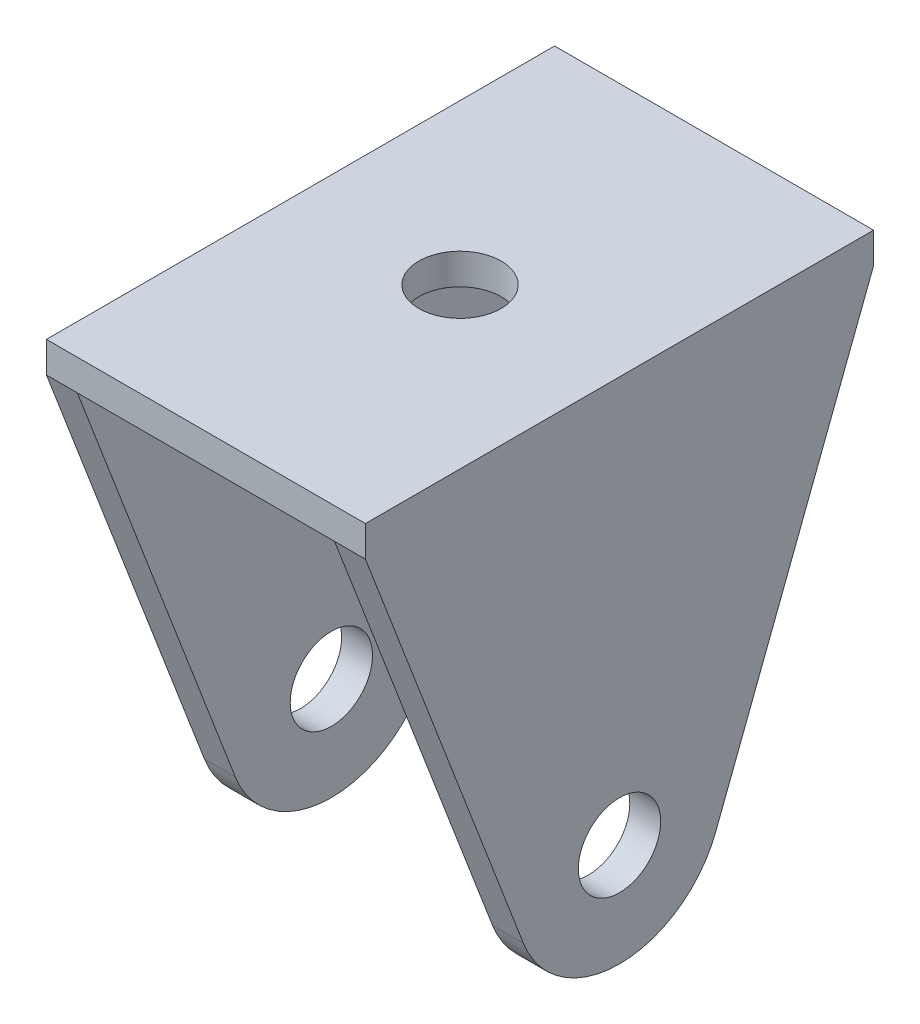
from build123d import *

# Parameters (mm, degrees)
CROQUIS1_R              = 4
SALIENTE_EXTRUIR1_DEPTH = 3
CROQUIS2_R              = 4
SALIENTE_EXTRUIR2_DEPTH = 3
CROQUIS3_W              = 31
CROQUIS3_H              = 49.380731332
SALIENTE_EXTRUIR3_DEPTH = 3
CROQUIS5_R              = 4
CORTAR_EXTRUIR1_DEPTH   = 3


with BuildPart() as part:
    # Croquis1 → Saliente-Extruir1 (new body)
    with BuildSketch(Plane(origin=(0, 0, 0), x_dir=(0, 0, -1), z_dir=(1, 0, 0))):
        with BuildLine():
            Line((-9.335804265, -3.583679495), (-24.690365666, 36.416320505))
            Line((-24.690365666, 36.416320505), (24.690365666, 36.416320505))
            Line((24.690365666, 36.416320505), (9.335804265, -3.583679495))
            ThreePointArc((9.335804265, -3.583679495), (0, -10), (-9.335804265, -3.583679495))
        make_face()
        Circle(CROQUIS1_R, mode=Mode.SUBTRACT)
    extrude(amount=SALIENTE_EXTRUIR1_DEPTH)



with BuildPart() as body_2:
    # Croquis2 → Saliente-Extruir2 (new body)
    with BuildSketch(Plane.ZY.offset(25)):
        with BuildLine():
            Line((9.335804265, -3.583679495), (24.690365666, 36.416320505))
            Line((24.690365666, 36.416320505), (-24.690365666, 36.416320505))
            Line((-24.690365666, 36.416320505), (-9.335804265, -3.583679495))
            ThreePointArc((-9.335804265, -3.583679495), (0, -10), (9.335804265, -3.583679495))
        make_face()
        Circle(CROQUIS2_R, mode=Mode.SUBTRACT)
    extrude(amount=SALIENTE_EXTRUIR2_DEPTH)


with BuildPart() as part_1:
    add(part.part)

    add(body_2.part)  # Saliente-Extruir3 merges body 2
    # Croquis3 → Saliente-Extruir3 (add)
    with BuildSketch(Plane(origin=(0, 36.416320505, 0), x_dir=(1, 0, 0), z_dir=(0, 1, 0))):
        with Locations((-12.5, 0)):
            Rectangle(CROQUIS3_W, CROQUIS3_H)
    extrude(amount=SALIENTE_EXTRUIR3_DEPTH)

    # Croquis5 → Cortar-Extruir1 (cut)
    with BuildSketch(Plane(origin=(0, 39.416320505, 0), x_dir=(1, 0, 0), z_dir=(0, 1, 0))):
        with Locations((-12.5, 0)):
            Circle(CROQUIS5_R)
    extrude(amount=-CORTAR_EXTRUIR1_DEPTH, mode=Mode.SUBTRACT)


solid = part_1.part
